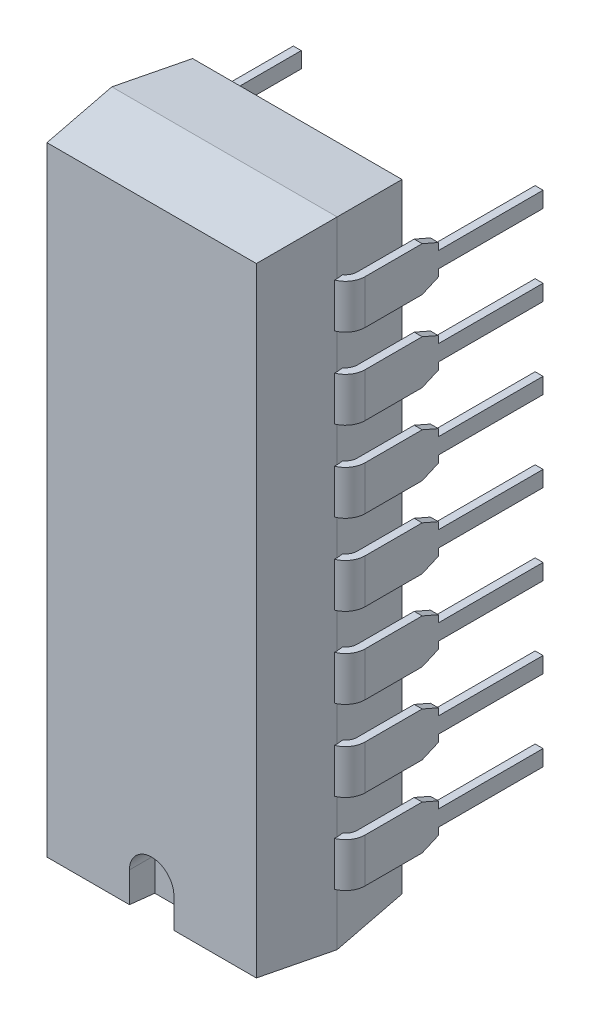
from build123d import *

# Parameters (mm, degrees)
BASIC_SHAPE_DEPTH          = 10
SIDE_PROFILE1_DEPTH        = 12.773380993
SIDE_PROFILE1_DEPTH_BACK   = 12.773380993
SIDE_PROFILE2_DEPTH        = 12.773380993
SIDE_PROFILE2_DEPTH_BACK   = 12.773380993
LOCATION_MARK_DEPTH        = 0.8
SKETCH6_W                  = 0.25
SKETCH6_H                  = 1.39
PIN_RELIEF_DEPTH           = 14.354970049
UPPER_PINS_COUNT           = 4
UPPER_PINS_PITCH           = 2.54
UPPER_PINS_COPY_1_SKETCH_W = 0.25
UPPER_PINS_COPY_1_SKETCH_H = 1.39
UPPER_PINS_COPY_2_SKETCH_W = 0.25
UPPER_PINS_COPY_2_SKETCH_H = 1.39
UPPER_PINS_COPY_3_SKETCH_W = 0.25
UPPER_PINS_COPY_3_SKETCH_H = 1.39
UPPER_PINS_COPY_4_DEPTH    = 14.354970049
UPPER_PINS_COPY_5_DEPTH    = 14.354970049
UPPER_PINS_COPY_6_DEPTH    = 14.354970049
LOWER_PINS_COUNT           = 4
LOWER_PINS_PITCH           = 2.54
LOWER_PINS_COPY_1_SKETCH_W = 0.25
LOWER_PINS_COPY_1_SKETCH_H = 1.39
LOWER_PINS_COPY_2_SKETCH_W = 0.25
LOWER_PINS_COPY_2_SKETCH_H = 1.39
LOWER_PINS_COPY_3_SKETCH_W = 0.25
LOWER_PINS_COPY_3_SKETCH_H = 1.39
LOWER_PINS_COPY_4_DEPTH    = 14.354970049
LOWER_PINS_COPY_5_DEPTH    = 14.354970049
LOWER_PINS_COPY_6_DEPTH    = 14.354970049


with BuildPart() as part:
    # Sketch1 → Basic Shape (new, symmetric)
    with BuildSketch(Plane(origin=(0, 0, 0), x_dir=(1, 0, 0), z_dir=(0, 1, 0))):
        Polygon((-3.3, -5.1), (-3.55, -2.805), (-3.3, -0.51), (3.3, -0.51), (3.55, -2.805), (3.3, -5.1), align=None)
    extrude(amount=BASIC_SHAPE_DEPTH, both=True)

    # Sketch2 → Side Profile1 (cut, two sides)
    with BuildSketch(Plane(origin=(0, 0, 0), x_dir=(0, 0, -1), z_dir=(1, 0, 0))) as side_profile1_sk:
        Polygon((-0.51, 10), (-0.51, 9.75), (-2.805, 10), align=None)
        Polygon((-0.51, -10), (-2.805, -10), (-0.51, -9.75), align=None)
    extrude(amount=SIDE_PROFILE1_DEPTH, mode=Mode.SUBTRACT)
    extrude(side_profile1_sk.sketch, amount=-SIDE_PROFILE1_DEPTH_BACK, mode=Mode.SUBTRACT)

    # Sketch3 → Side Profile2 (cut, two sides)
    with BuildSketch(Plane(origin=(0, 0, 0), x_dir=(0, 0, -1), z_dir=(1, 0, 0))) as side_profile2_sk:
        Polygon((-2.805, 10), (-5.1, 10), (-5.1, 9.75), align=None)
        Polygon((-2.805, -10), (-5.1, -10), (-5.1, -9.75), align=None)
    extrude(amount=SIDE_PROFILE2_DEPTH, mode=Mode.SUBTRACT)
    extrude(side_profile2_sk.sketch, amount=-SIDE_PROFILE2_DEPTH_BACK, mode=Mode.SUBTRACT)

    # Sketch4 → Location Mark (cut)
    with BuildSketch(Plane.XY.offset(5.1)):
        with BuildLine():
            Line((-0.7, -10), (-0.7, -8.8))
            ThreePointArc((-0.7, -8.8), (0, -8.1), (0.7, -8.8))
            Line((0.7, -8.8), (0.7, -10))
            Line((0.7, -10), (-0.7, -10))
        make_face()
    extrude(amount=-LOCATION_MARK_DEPTH, mode=Mode.SUBTRACT)

    # Central Pin: sweep along a path in Sketch5
    with BuildLine(Plane(origin=(0, 0, 0), x_dir=(1, 0, 0), z_dir=(0, 1, 0))) as central_pin_path:
        Line((0, -2.805), (3.31, -2.805))
        ThreePointArc((3.31, -2.805), (3.663553391, -2.658553391), (3.81, -2.305))
        Line((3.81, -2.305), (3.81, 3.3))
    # Sketch6 → Central Pin (sweep)
    with BuildSketch(Plane(origin=(0, 0, 0), x_dir=(0, 0, -1), z_dir=(1, 0, 0))):
        with Locations((-2.805, 0)):
            Rectangle(SKETCH6_W, SKETCH6_H)
    central_pin = sweep(path=central_pin_path.line)

    # Sketch7 → Pin Relief (cut, through all)
    with BuildSketch(Plane.ZY.offset(-3.685)):
        Polygon((-3.3, -0.25), (0, -0.25), (0, -0.4725), (0.51, -0.695), (-3.3, -0.695), align=None)
        Polygon((-3.3, 0.25), (0, 0.25), (0, 0.4725), (0.51, 0.695), (-3.3, 0.695), align=None)
    pin_relief = extrude(amount=-PIN_RELIEF_DEPTH, mode=Mode.SUBTRACT)

    # Opp Pin: Central Pin, Pin Relief across plane
    add(central_pin.mirror(Plane(origin=(0, 0, 0), x_dir=(0, 0, 1), z_dir=(1, 0, 0))))
    add(pin_relief.mirror(Plane(origin=(0, 0, 0), x_dir=(0, 0, 1), z_dir=(1, 0, 0))), mode=Mode.SUBTRACT)

    # Upper Pins: Central Pin, Pin Relief ×4
    with Locations(*[(0, -i * UPPER_PINS_PITCH, 0) for i in range(1, UPPER_PINS_COUNT)]):
        add(central_pin)
        add(pin_relief, mode=Mode.SUBTRACT)

    # Upper Pins copy 1: sweep along a path in Upper Pins copy 1 path
    with BuildLine(Plane(origin=(0, -2.54, 0), x_dir=(-1, 0, 0), z_dir=(0, 1, 0))) as upper_pins_copy_1_path:
        Line((0, 2.805), (3.31, 2.805))
        ThreePointArc((3.31, 2.805), (3.663553391, 2.658553391), (3.81, 2.305))
        Line((3.81, 2.305), (3.81, -3.3))
    # Upper Pins copy 1 sketch → Upper Pins copy 1 (sweep)
    with BuildSketch(Plane(origin=(0, -2.54, 0), x_dir=(0, 0, -1), z_dir=(-1, 0, 0))):
        with Locations((-2.805, 0)):
            Rectangle(UPPER_PINS_COPY_1_SKETCH_W, UPPER_PINS_COPY_1_SKETCH_H)
    sweep(path=upper_pins_copy_1_path.line)

    # Upper Pins copy 2: sweep along a path in Upper Pins copy 2 path
    with BuildLine(Plane(origin=(0, -5.08, 0), x_dir=(-1, 0, 0), z_dir=(0, 1, 0))) as upper_pins_copy_2_path:
        Line((0, 2.805), (3.31, 2.805))
        ThreePointArc((3.31, 2.805), (3.663553391, 2.658553391), (3.81, 2.305))
        Line((3.81, 2.305), (3.81, -3.3))
    # Upper Pins copy 2 sketch → Upper Pins copy 2 (sweep)
    with BuildSketch(Plane(origin=(0, -5.08, 0), x_dir=(0, 0, -1), z_dir=(-1, 0, 0))):
        with Locations((-2.805, 0)):
            Rectangle(UPPER_PINS_COPY_2_SKETCH_W, UPPER_PINS_COPY_2_SKETCH_H)
    sweep(path=upper_pins_copy_2_path.line)

    # Upper Pins copy 3: sweep along a path in Upper Pins copy 3 path
    with BuildLine(Plane(origin=(0, -7.62, 0), x_dir=(-1, 0, 0), z_dir=(0, 1, 0))) as upper_pins_copy_3_path:
        Line((0, 2.805), (3.31, 2.805))
        ThreePointArc((3.31, 2.805), (3.663553391, 2.658553391), (3.81, 2.305))
        Line((3.81, 2.305), (3.81, -3.3))
    # Upper Pins copy 3 sketch → Upper Pins copy 3 (sweep)
    with BuildSketch(Plane(origin=(0, -7.62, 0), x_dir=(0, 0, -1), z_dir=(-1, 0, 0))):
        with Locations((-2.805, 0)):
            Rectangle(UPPER_PINS_COPY_3_SKETCH_W, UPPER_PINS_COPY_3_SKETCH_H)
    sweep(path=upper_pins_copy_3_path.line)

    # Upper Pins copy 4 sketch → Upper Pins copy 4 (cut, through all)
    with BuildSketch(Plane(origin=(-3.685, -2.54, 0), x_dir=(0, 0, 1), z_dir=(1, 0, 0))):
        Polygon((-3.3, 0.25), (0, 0.25), (0, 0.4725), (0.51, 0.695), (-3.3, 0.695), align=None)
        Polygon((-3.3, -0.25), (0, -0.25), (0, -0.4725), (0.51, -0.695), (-3.3, -0.695), align=None)
    extrude(amount=-UPPER_PINS_COPY_4_DEPTH, mode=Mode.SUBTRACT)

    # Upper Pins copy 5 sketch → Upper Pins copy 5 (cut, through all)
    with BuildSketch(Plane(origin=(-3.685, -5.08, 0), x_dir=(0, 0, 1), z_dir=(1, 0, 0))):
        Polygon((-3.3, 0.25), (0, 0.25), (0, 0.4725), (0.51, 0.695), (-3.3, 0.695), align=None)
        Polygon((-3.3, -0.25), (0, -0.25), (0, -0.4725), (0.51, -0.695), (-3.3, -0.695), align=None)
    extrude(amount=-UPPER_PINS_COPY_5_DEPTH, mode=Mode.SUBTRACT)

    # Upper Pins copy 6 sketch → Upper Pins copy 6 (cut, through all)
    with BuildSketch(Plane(origin=(-3.685, -7.62, 0), x_dir=(0, 0, 1), z_dir=(1, 0, 0))):
        Polygon((-3.3, 0.25), (0, 0.25), (0, 0.4725), (0.51, 0.695), (-3.3, 0.695), align=None)
        Polygon((-3.3, -0.25), (0, -0.25), (0, -0.4725), (0.51, -0.695), (-3.3, -0.695), align=None)
    extrude(amount=-UPPER_PINS_COPY_6_DEPTH, mode=Mode.SUBTRACT)

    # Lower Pins: Central Pin, Pin Relief ×4
    with Locations(*[(0, i * LOWER_PINS_PITCH, 0) for i in range(1, LOWER_PINS_COUNT)]):
        add(central_pin)
        add(pin_relief, mode=Mode.SUBTRACT)

    # Lower Pins copy 1: sweep along a path in Lower Pins copy 1 path
    with BuildLine(Plane(origin=(0, 2.54, 0), x_dir=(-1, 0, 0), z_dir=(0, 1, 0))) as lower_pins_copy_1_path:
        Line((0, 2.805), (3.31, 2.805))
        ThreePointArc((3.31, 2.805), (3.663553391, 2.658553391), (3.81, 2.305))
        Line((3.81, 2.305), (3.81, -3.3))
    # Lower Pins copy 1 sketch → Lower Pins copy 1 (sweep)
    with BuildSketch(Plane(origin=(0, 2.54, 0), x_dir=(0, 0, -1), z_dir=(-1, 0, 0))):
        with Locations((-2.805, 0)):
            Rectangle(LOWER_PINS_COPY_1_SKETCH_W, LOWER_PINS_COPY_1_SKETCH_H)
    sweep(path=lower_pins_copy_1_path.line)

    # Lower Pins copy 2: sweep along a path in Lower Pins copy 2 path
    with BuildLine(Plane(origin=(0, 5.08, 0), x_dir=(-1, 0, 0), z_dir=(0, 1, 0))) as lower_pins_copy_2_path:
        Line((0, 2.805), (3.31, 2.805))
        ThreePointArc((3.31, 2.805), (3.663553391, 2.658553391), (3.81, 2.305))
        Line((3.81, 2.305), (3.81, -3.3))
    # Lower Pins copy 2 sketch → Lower Pins copy 2 (sweep)
    with BuildSketch(Plane(origin=(0, 5.08, 0), x_dir=(0, 0, -1), z_dir=(-1, 0, 0))):
        with Locations((-2.805, 0)):
            Rectangle(LOWER_PINS_COPY_2_SKETCH_W, LOWER_PINS_COPY_2_SKETCH_H)
    sweep(path=lower_pins_copy_2_path.line)

    # Lower Pins copy 3: sweep along a path in Lower Pins copy 3 path
    with BuildLine(Plane(origin=(0, 7.62, 0), x_dir=(-1, 0, 0), z_dir=(0, 1, 0))) as lower_pins_copy_3_path:
        Line((0, 2.805), (3.31, 2.805))
        ThreePointArc((3.31, 2.805), (3.663553391, 2.658553391), (3.81, 2.305))
        Line((3.81, 2.305), (3.81, -3.3))
    # Lower Pins copy 3 sketch → Lower Pins copy 3 (sweep)
    with BuildSketch(Plane(origin=(0, 7.62, 0), x_dir=(0, 0, -1), z_dir=(-1, 0, 0))):
        with Locations((-2.805, 0)):
            Rectangle(LOWER_PINS_COPY_3_SKETCH_W, LOWER_PINS_COPY_3_SKETCH_H)
    sweep(path=lower_pins_copy_3_path.line)

    # Lower Pins copy 4 sketch → Lower Pins copy 4 (cut, through all)
    with BuildSketch(Plane(origin=(-3.685, 2.54, 0), x_dir=(0, 0, 1), z_dir=(1, 0, 0))):
        Polygon((-3.3, 0.25), (0, 0.25), (0, 0.4725), (0.51, 0.695), (-3.3, 0.695), align=None)
        Polygon((-3.3, -0.25), (0, -0.25), (0, -0.4725), (0.51, -0.695), (-3.3, -0.695), align=None)
    extrude(amount=-LOWER_PINS_COPY_4_DEPTH, mode=Mode.SUBTRACT)

    # Lower Pins copy 5 sketch → Lower Pins copy 5 (cut, through all)
    with BuildSketch(Plane(origin=(-3.685, 5.08, 0), x_dir=(0, 0, 1), z_dir=(1, 0, 0))):
        Polygon((-3.3, 0.25), (0, 0.25), (0, 0.4725), (0.51, 0.695), (-3.3, 0.695), align=None)
        Polygon((-3.3, -0.25), (0, -0.25), (0, -0.4725), (0.51, -0.695), (-3.3, -0.695), align=None)
    extrude(amount=-LOWER_PINS_COPY_5_DEPTH, mode=Mode.SUBTRACT)

    # Lower Pins copy 6 sketch → Lower Pins copy 6 (cut, through all)
    with BuildSketch(Plane(origin=(-3.685, 7.62, 0), x_dir=(0, 0, 1), z_dir=(1, 0, 0))):
        Polygon((-3.3, 0.25), (0, 0.25), (0, 0.4725), (0.51, 0.695), (-3.3, 0.695), align=None)
        Polygon((-3.3, -0.25), (0, -0.25), (0, -0.4725), (0.51, -0.695), (-3.3, -0.695), align=None)
    extrude(amount=-LOWER_PINS_COPY_6_DEPTH, mode=Mode.SUBTRACT)


solid = part.part
